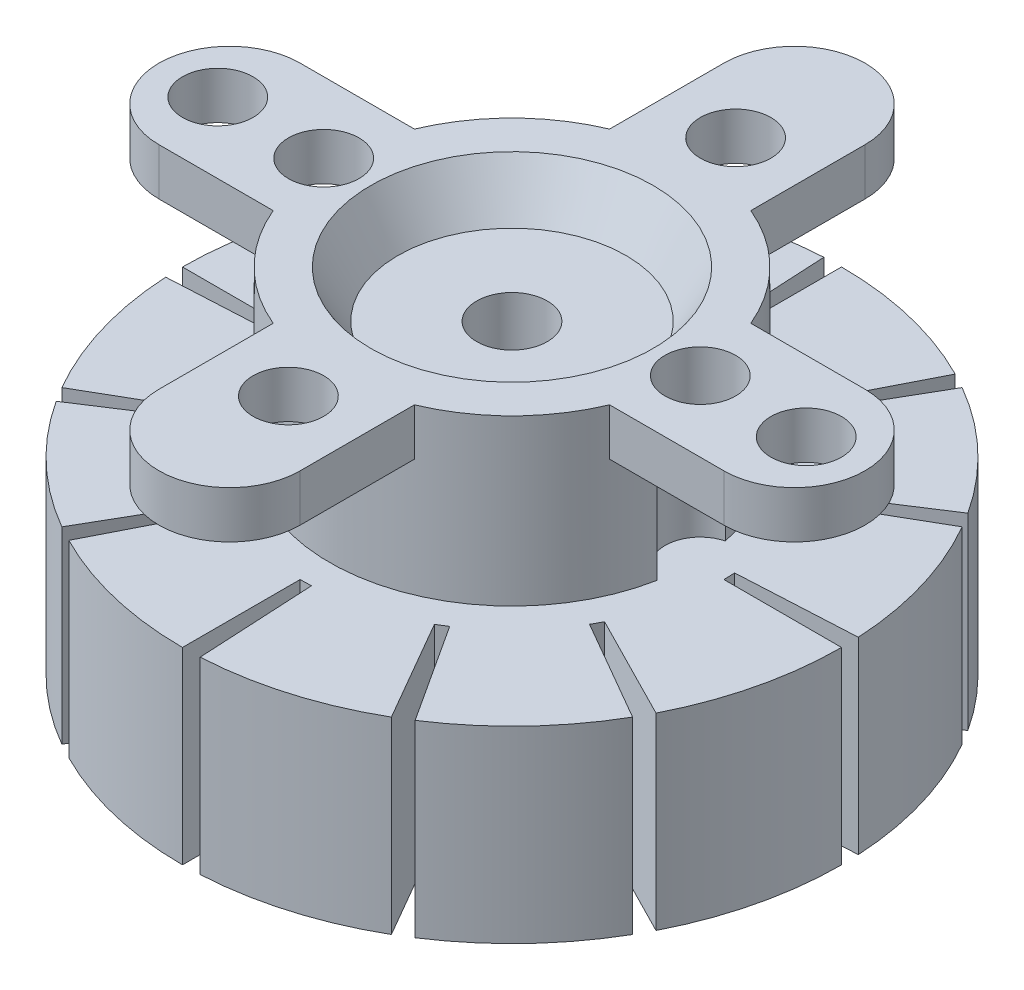
from build123d import *

# Parameters (mm, degrees)
SKETCH1_W           = 6
SKETCH1_H           = 6
BOSS_EXTRUDE1_DEPTH = 2
SKETCH2_R           = 1.5
CUT_EXTRUDE1_DEPTH  = 3
SKETCH3_R           = 6
CUT_EXTRUDE2_DEPTH  = 3
CUT_EXTRUDE2_TAPER  = 30
BOSS_EXTRUDE2_DEPTH = 13
SKETCH5_R           = 14
BOSS_EXTRUDE3_DEPTH = 8
SKETCH6_R           = 1.5
CUT_EXTRUDE3_DEPTH  = 14
CUT_EXTRUDE5_DEPTH  = 8
CIRPATTERN1_COUNT   = 12


with BuildPart() as part:
    # Sketch1 → Boss-Extrude1 (new body)
    with BuildSketch(Plane(origin=(0, 0, 0), x_dir=(1, 0, 0), z_dir=(0, 1, 0))):
        with BuildLine():
            Line((-12, -3), (-7.145802964, -3))
            ThreePointArc((-7.145802964, -3), (-7.75, 0), (-7.145802964, 3))
            Line((-7.145802964, 3), (-12, 3))
            ThreePointArc((-12, 3), (-15, 0), (-12, -3))
        make_face()
        with BuildLine():
            Line((-7.145802964, -3), (-3, -3))
            Line((-3, -3), (-3, 3))
            Line((-3, 3), (-7.145802964, 3))
            ThreePointArc((-7.145802964, 3), (-7.75, 0), (-7.145802964, -3))
        make_face()
        with BuildLine():
            Line((3, -3), (3, -7.145802964))
            ThreePointArc((3, -7.145802964), (5.480077554, -5.480077554), (7.145802964, -3))
            Line((7.145802964, -3), (3, -3))
        make_face()
        with BuildLine():
            Line((-3, -3), (-3, -7.145802964))
            ThreePointArc((-3, -7.145802964), (0, -7.75), (3, -7.145802964))
            Line((3, -7.145802964), (3, -3))
            Line((3, -3), (-3, -3))
        make_face()
        with BuildLine():
            ThreePointArc((-7.145802964, -3), (-5.480077554, -5.480077554), (-3, -7.145802964))
            Line((-3, -7.145802964), (-3, -3))
            Line((-3, -3), (-7.145802964, -3))
        make_face()
        with BuildLine():
            Line((-7.145802964, 3), (-3, 3))
            Line((-3, 3), (-3, 7.145802964))
            ThreePointArc((-3, 7.145802964), (-5.480077554, 5.480077554), (-7.145802964, 3))
        make_face()
        with BuildLine():
            Line((-3, 7.145802964), (-3, 3))
            Line((-3, 3), (3, 3))
            Line((3, 3), (3, 7.145802964))
            ThreePointArc((3, 7.145802964), (0, 7.75), (-3, 7.145802964))
        make_face()
        with BuildLine():
            Line((-3, 12), (-3, 7.145802964))
            ThreePointArc((-3, 7.145802964), (0, 7.75), (3, 7.145802964))
            Line((3, 7.145802964), (3, 12))
            ThreePointArc((3, 12), (0, 15), (-3, 12))
        make_face()
        Rectangle(SKETCH1_W, SKETCH1_H)
        with BuildLine():
            Line((3, 3), (3, -3))
            Line((3, -3), (7.145802964, -3))
            ThreePointArc((7.145802964, -3), (7.597449341, -1.530118791), (7.75, 0))
            ThreePointArc((7.75, 0), (7.597449341, 1.530118791), (7.145802964, 3))
            Line((7.145802964, 3), (3, 3))
        make_face()
        with BuildLine():
            Line((3, 7.145802964), (3, 3))
            Line((3, 3), (7.145802964, 3))
            ThreePointArc((7.145802964, 3), (5.480077554, 5.480077554), (3, 7.145802964))
        make_face()
        with BuildLine():
            ThreePointArc((7.75, 0), (7.597449341, -1.530118791), (7.145802964, -3))
            Line((7.145802964, -3), (12, -3))
            ThreePointArc((12, -3), (15, 0), (12, 3))
            Line((12, 3), (7.145802964, 3))
            ThreePointArc((7.145802964, 3), (7.597449341, 1.530118791), (7.75, 0))
        make_face()
        with BuildLine():
            Line((-3, -7.145802964), (-3, -12))
            ThreePointArc((-3, -12), (0, -15), (3, -12))
            Line((3, -12), (3, -7.145802964))
            ThreePointArc((3, -7.145802964), (0, -7.75), (-3, -7.145802964))
        make_face()
    extrude(amount=BOSS_EXTRUDE1_DEPTH)

    # Sketch2 → Cut-Extrude1 (cut, through all)
    with BuildSketch(Plane(origin=(0, 2, 0), x_dir=(1, 0, 0), z_dir=(0, 1, 0))):
        with Locations((8, 0)):
            Circle(SKETCH2_R)
        with Locations((12.5, 0)):
            Circle(SKETCH2_R)
        with Locations((0, 9.5)):
            Circle(SKETCH2_R)
        with Locations((0, -9.5)):
            Circle(SKETCH2_R)
        with Locations((-12.5, 0)):
            Circle(SKETCH2_R)
        with Locations((-8, 0)):
            Circle(SKETCH2_R)
    extrude(amount=-CUT_EXTRUDE1_DEPTH, mode=Mode.SUBTRACT)

    # Sketch3 → Cut-Extrude2 (cut, through all)
    with BuildSketch(Plane(origin=(0, 2, 0), x_dir=(1, 0, 0), z_dir=(0, 1, 0))):
        Circle(SKETCH3_R)
    extrude(amount=-CUT_EXTRUDE2_DEPTH, taper=CUT_EXTRUDE2_TAPER, mode=Mode.SUBTRACT)

    # Sketch4 → Boss-Extrude2 (add)
    with BuildSketch(Plane.XZ):
        with BuildLine():
            ThreePointArc((-7.61328125, -1.449292451), (0, -7.75), (7.61328125, -1.449292451))
            ThreePointArc((7.61328125, -1.449292451), (6.5, 0), (7.61328125, 1.449292451))
            ThreePointArc((7.61328125, 1.449292451), (0, 7.75), (-7.61328125, 1.449292451))
            ThreePointArc((-7.61328125, 1.449292451), (-6.5, 0), (-7.61328125, -1.449292451))
        make_face()
    extrude(amount=BOSS_EXTRUDE2_DEPTH)

    # Sketch5 → Boss-Extrude3 (add)
    with BuildSketch(Plane.XZ.offset(13)):
        Circle(SKETCH5_R)
    extrude(amount=-BOSS_EXTRUDE3_DEPTH)

    # Sketch6 → Cut-Extrude3 (cut, through all)
    with BuildSketch(Plane(origin=(0, 0, 0), x_dir=(1, 0, 0), z_dir=(0, 1, 0))):
        Circle(SKETCH6_R)
    extrude(amount=-CUT_EXTRUDE3_DEPTH, mode=Mode.SUBTRACT)

    # Sketch7 → Cut-Extrude5 (cut)
    with BuildSketch(Plane.XZ.offset(13)):
        with BuildLine():
            Line((14, 0), (9, 0))
            ThreePointArc((9, 0), (8.996915925, -0.235592535), (8.987665813, -0.471023606))
            Line((8.987665813, -0.471023606), (13.980813487, -0.732703387))
            ThreePointArc((13.980813487, -0.732703387), (13.99520255, -0.366477276), (14, 0))
        make_face()
    cut_extrude5 = extrude(amount=-CUT_EXTRUDE5_DEPTH, mode=Mode.SUBTRACT)

    # CirPattern1: Cut-Extrude5 ×12 about axis
    cirpattern1_axis = Axis((0, -13, 0), (0, -1, 0))
    for i in range(1, CIRPATTERN1_COUNT):
        add(cut_extrude5.rotate(cirpattern1_axis, i * 360 / CIRPATTERN1_COUNT), mode=Mode.SUBTRACT)


solid = part.part
